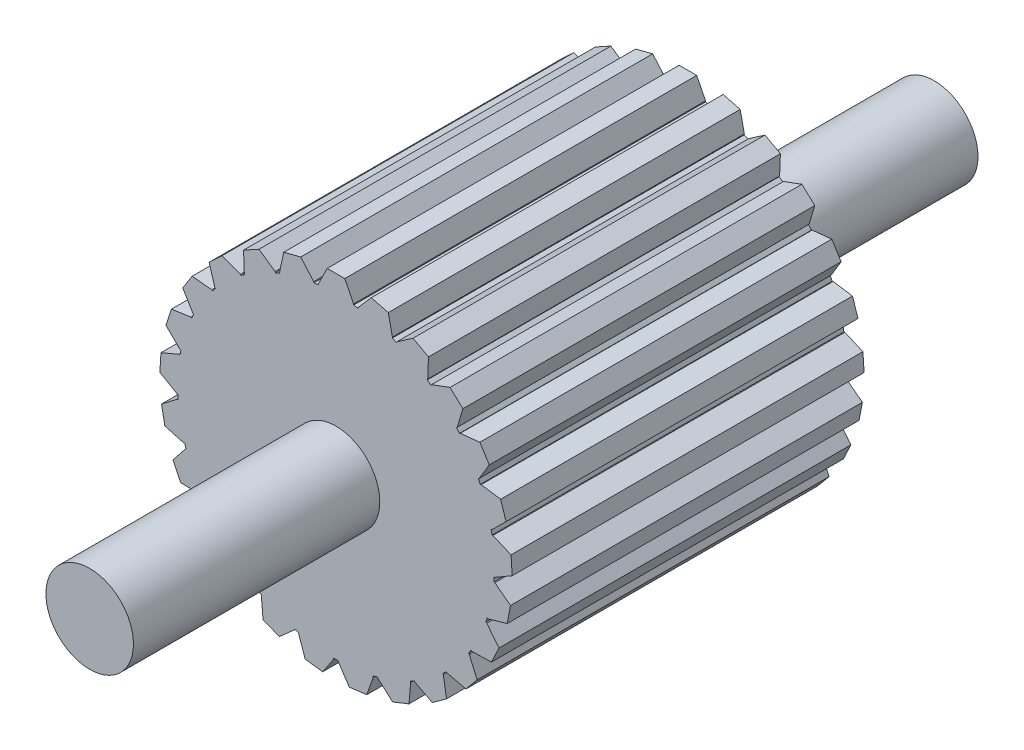
from build123d import *

# Parameters (mm, degrees)
SKETCH1_R           = 24.875
BOSS_EXTRUDE1_DEPTH = 480
SKETCH2_R           = 90
BOSS_EXTRUDE2_DEPTH = 100
BOSS_EXTRUDE3_DEPTH = 200
CIRPATTERN1_COUNT   = 25


with BuildPart() as part:
    # Sketch1 → Boss-Extrude1 (new body)
    with BuildSketch(Plane.XY):
        Circle(SKETCH1_R)
    extrude(amount=BOSS_EXTRUDE1_DEPTH)

    # Sketch2 → Boss-Extrude2 (add, symmetric)
    with BuildSketch(Plane.XY.offset(240)):
        Circle(SKETCH2_R)
    extrude(amount=BOSS_EXTRUDE2_DEPTH, both=True)

    # Sketch3 → Boss-Extrude3 (add)
    with BuildSketch(Plane.XY.offset(340)):
        with BuildLine():
            ThreePointArc((10, 89.4427191), (0, 90), (-10, 89.4427191))
            Line((-10, 89.4427191), (-10, 80))
            Line((-10, 80), (10, 80))
            Line((10, 80), (10, 89.4427191))
        make_face()
        with BuildLine():
            Line((-10, 80), (-10, 89.4427191))
            ThreePointArc((-10, 89.4427191), (-60, -67.082039325), (90, 0))
            ThreePointArc((90, 0), (67.082039325, 60), (10, 89.4427191))
            Line((10, 89.4427191), (10, 80))
            Line((10, 80), (-10, 80))
        make_face()
        with BuildLine():
            Line((-5, 100), (-10, 90))
            Line((-10, 90), (-10, 89.4427191))
            ThreePointArc((-10, 89.4427191), (0, 90), (10, 89.4427191))
            Line((10, 89.4427191), (10, 90))
            Line((10, 90), (5, 100))
            Line((5, 100), (-5, 100))
        make_face()
    boss_extrude3 = extrude(amount=-BOSS_EXTRUDE3_DEPTH)

    # CirPattern1: Boss-Extrude3 ×25 about axis
    cirpattern1_axis = Axis((0, 0, 0), (0, 0, 1))
    for i in range(1, CIRPATTERN1_COUNT):
        add(boss_extrude3.rotate(cirpattern1_axis, i * 360 / CIRPATTERN1_COUNT))


solid = part.part
